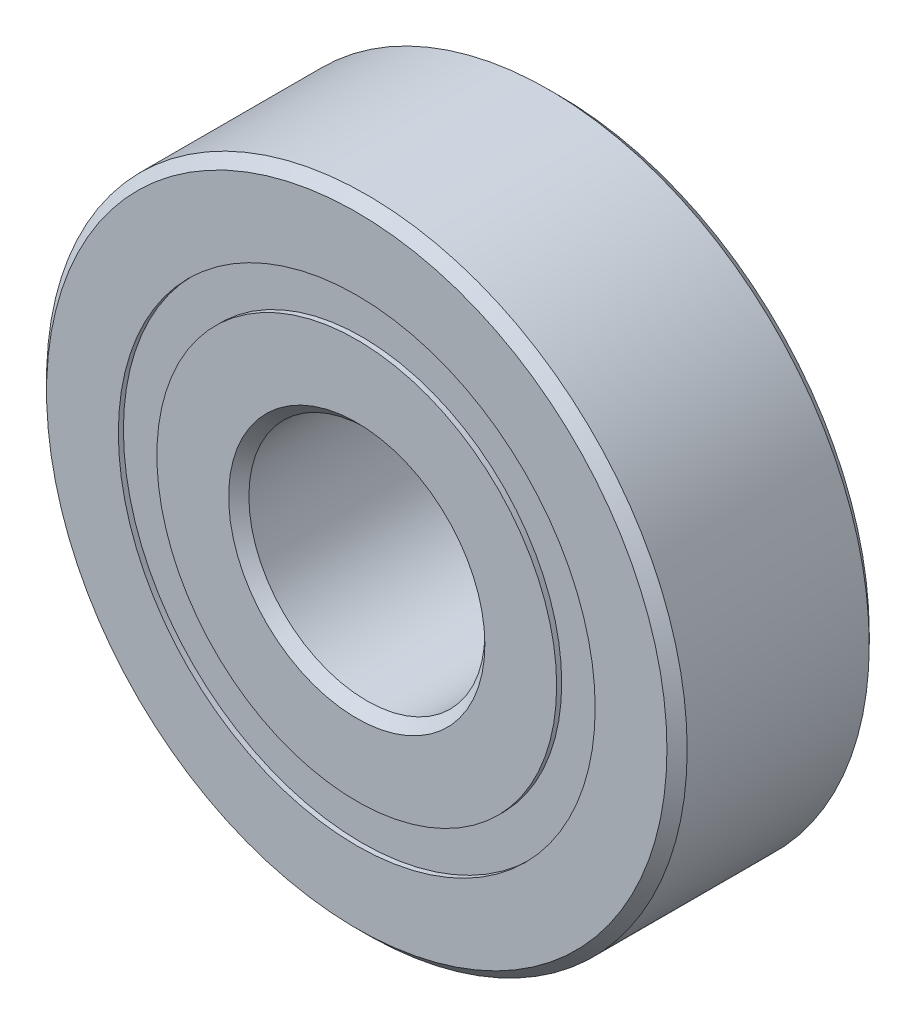
from build123d import *

# Parameters (mm, degrees)
CIRPATTERN1_COUNT = 12
SKETCH5_W         = 1.399376551
SKETCH5_H         = 1.142857142


with BuildPart() as part:
    # Sketch6 → Revolve1 (revolve)
    with BuildSketch(Plane(origin=(0, 0, 0), x_dir=(0, 0, -1), z_dir=(1, 0, 0))):
        with BuildLine():
            Line((-3, 9.2), (-3, 7.071428571))
            Line((-3, 7.071428571), (-1.333333333, 7.071428571))
            ThreePointArc((-1.333333333, 7.071428571), (0, 7.950623449), (1.333333333, 7.071428571))
            Line((1.333333333, 7.071428571), (3, 7.071428571))
            Line((3, 7.071428571), (3, 9.2))
            Line((3, 9.2), (2.7, 9.5))
            Line((2.7, 9.5), (-2.7, 9.5))
            Line((-2.7, 9.5), (-3, 9.2))
        make_face()
        with BuildLine():
            Line((-3, 3.8), (-3, 5.928571429))
            Line((-3, 5.928571429), (-1.333333333, 5.928571429))
            ThreePointArc((-1.333333333, 5.928571429), (0, 5.049376551), (1.333333333, 5.928571429))
            Line((1.333333333, 5.928571429), (3, 5.928571429))
            Line((3, 5.928571429), (3, 3.8))
            Line((3, 3.8), (2.7, 3.5))
            Line((2.7, 3.5), (-2.7, 3.5))
            Line((-2.7, 3.5), (-3, 3.8))
        make_face()
    revolve(axis=Axis((0, 0, 3), (0, 0, -1)))



with BuildPart() as body_2:
    # Sketch4 → Revolve2 (revolve)
    with BuildSketch(Plane(origin=(0, 0, 0), x_dir=(0, 0, -1), z_dir=(1, 0, 0))):
        with BuildLine():
            Line((-1.450623449, 6.5), (1.450623449, 6.5))
            ThreePointArc((1.450623449, 6.5), (0, 7.950623449), (-1.450623449, 6.5))
        make_face()
    revolve(axis=Axis((0, 6.5, 1.450623449), (0, 0, -1)))


with BuildPart() as cirpattern1_1:
    # CirPattern1: pattern copy
    add(body_2.part.rotate(Axis((0, 0, -3), (0, 0, 1)), 1 * 360 / CIRPATTERN1_COUNT))


with BuildPart() as cirpattern1_2:
    # CirPattern1: pattern copy
    add(body_2.part.rotate(Axis((0, 0, -3), (0, 0, 1)), 2 * 360 / CIRPATTERN1_COUNT))


with BuildPart() as cirpattern1_3:
    # CirPattern1: pattern copy
    add(body_2.part.rotate(Axis((0, 0, -3), (0, 0, 1)), 3 * 360 / CIRPATTERN1_COUNT))


with BuildPart() as cirpattern1_4:
    # CirPattern1: pattern copy
    add(body_2.part.rotate(Axis((0, 0, -3), (0, 0, 1)), 4 * 360 / CIRPATTERN1_COUNT))


with BuildPart() as cirpattern1_5:
    # CirPattern1: pattern copy
    add(body_2.part.rotate(Axis((0, 0, -3), (0, 0, 1)), 5 * 360 / CIRPATTERN1_COUNT))


with BuildPart() as cirpattern1_6:
    # CirPattern1: pattern copy
    add(body_2.part.rotate(Axis((0, 0, -3), (0, 0, 1)), 6 * 360 / CIRPATTERN1_COUNT))


with BuildPart() as cirpattern1_7:
    # CirPattern1: pattern copy
    add(body_2.part.rotate(Axis((0, 0, -3), (0, 0, 1)), 7 * 360 / CIRPATTERN1_COUNT))


with BuildPart() as cirpattern1_8:
    # CirPattern1: pattern copy
    add(body_2.part.rotate(Axis((0, 0, -3), (0, 0, 1)), 8 * 360 / CIRPATTERN1_COUNT))


with BuildPart() as cirpattern1_9:
    # CirPattern1: pattern copy
    add(body_2.part.rotate(Axis((0, 0, -3), (0, 0, 1)), 9 * 360 / CIRPATTERN1_COUNT))


with BuildPart() as cirpattern1_10:
    # CirPattern1: pattern copy
    add(body_2.part.rotate(Axis((0, 0, -3), (0, 0, 1)), 10 * 360 / CIRPATTERN1_COUNT))


with BuildPart() as cirpattern1_11:
    # CirPattern1: pattern copy
    add(body_2.part.rotate(Axis((0, 0, -3), (0, 0, 1)), 11 * 360 / CIRPATTERN1_COUNT))


with BuildPart() as part_1:
    add(part.part)

    add(body_2.part)  # Revolve3 merges body 2

    add(cirpattern1_1.part)  # Revolve3 merges CirPattern1_1

    add(cirpattern1_2.part)  # Revolve3 merges CirPattern1_2

    add(cirpattern1_3.part)  # Revolve3 merges CirPattern1_3

    add(cirpattern1_4.part)  # Revolve3 merges CirPattern1_4

    add(cirpattern1_5.part)  # Revolve3 merges CirPattern1_5

    add(cirpattern1_6.part)  # Revolve3 merges CirPattern1_6

    add(cirpattern1_7.part)  # Revolve3 merges CirPattern1_7

    add(cirpattern1_8.part)  # Revolve3 merges CirPattern1_8

    add(cirpattern1_9.part)  # Revolve3 merges CirPattern1_9

    add(cirpattern1_10.part)  # Revolve3 merges CirPattern1_10

    add(cirpattern1_11.part)  # Revolve3 merges CirPattern1_11
    # Sketch5 → Revolve3 (revolve)
    with BuildSketch(Plane(origin=(0, 0, 0), x_dir=(0, 0, -1), z_dir=(1, 0, 0))):
        with Locations((-2.150311724, 6.5)):
            Rectangle(SKETCH5_W, SKETCH5_H)
        with Locations((2.150311724, 6.5)):
            Rectangle(SKETCH5_W, SKETCH5_H)
    revolve(axis=Axis((0, 0, 3), (0, 0, -1)))


solid = part_1.part
